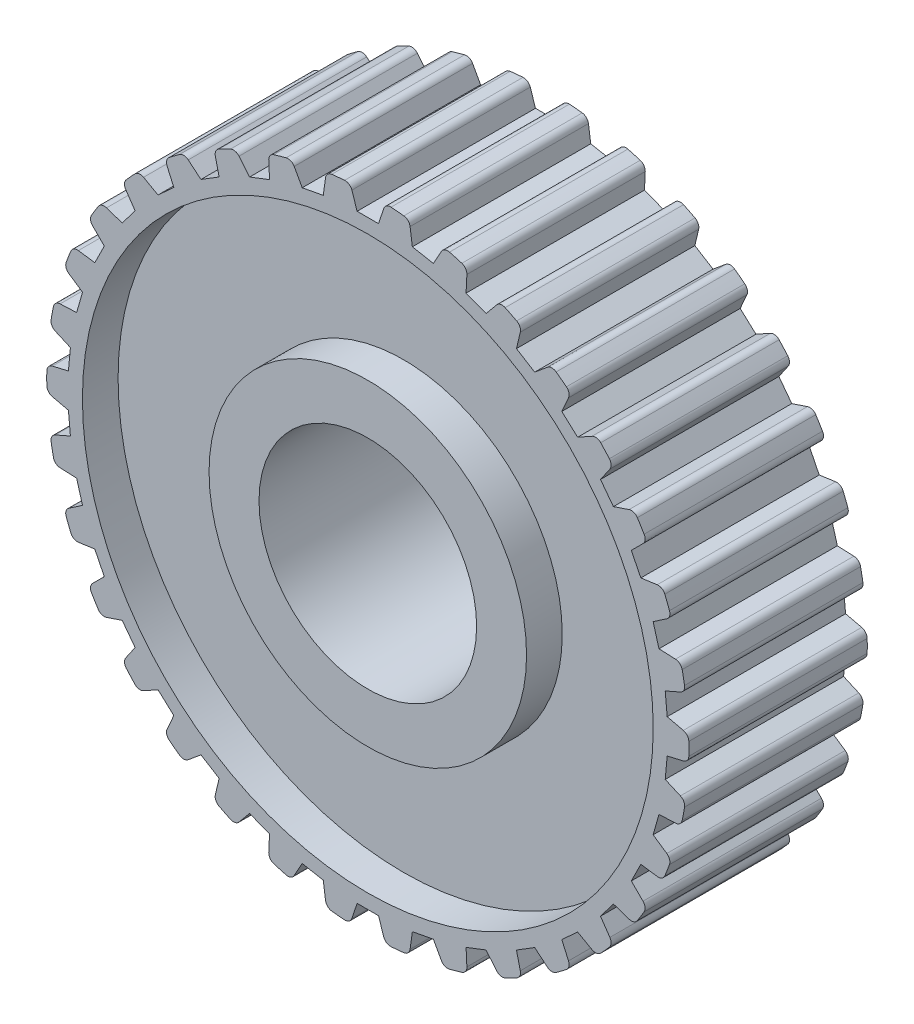
from build123d import *

# Parameters (mm, degrees)
SKETCH1_R                = 45
SKETCH1_R_2              = 40
BOSS_EXTRUDE1_DEPTH      = 25
SKETCH1_R_3              = 22.25
SKETCH1_R_4              = 15.25
BOSS_EXTRUDE1_2_DEPTH    = 25
SKETCH2_R                = 40
SKETCH2_R_2              = 22.25
BOSS_EXTRUDE2_DEPTH      = 7.5
BOSS_EXTRUDE2_DEPTH_BACK = 7.5
CUT_EXTRUDE2_DEPTH       = 26
FILLET1_R                = 1
CIRPATTERN1_COUNT        = 34
FILLET1_OF_CIRPATTERN1_R = 1


with BuildPart() as part:
    # Sketch1 → Boss-Extrude1 (new body)
    with BuildSketch(Plane.XY):
        Circle(SKETCH1_R)
        Circle(SKETCH1_R_2, mode=Mode.SUBTRACT)
    extrude(amount=BOSS_EXTRUDE1_DEPTH)



with BuildPart() as body_2:
    # Sketch1 → Boss-Extrude1 2 (new body)
    with BuildSketch(Plane.XY):
        Circle(SKETCH1_R_3)
        Circle(SKETCH1_R_4, mode=Mode.SUBTRACT)
    extrude(amount=BOSS_EXTRUDE1_2_DEPTH)


with BuildPart() as part_1:
    add(part.part)

    add(body_2.part)  # Boss-Extrude2 merges body 2
    # Sketch2 → Boss-Extrude2 (add, two sides)
    with BuildSketch(Plane.XY.offset(12.5)) as boss_extrude2_sk:
        Circle(SKETCH2_R)
        Circle(SKETCH2_R_2, mode=Mode.SUBTRACT)
    extrude(amount=BOSS_EXTRUDE2_DEPTH)
    extrude(boss_extrude2_sk.sketch, amount=-BOSS_EXTRUDE2_DEPTH_BACK)

    # Sketch4 → Cut-Extrude2 (cut, through all)
    with BuildSketch(Plane.XY.offset(25)):
        Polygon((-2.5, 45), (2.5, 45), (1.5, 42), (0, 42), (-1.5, 42), align=None)
    cut_extrude2 = extrude(amount=-CUT_EXTRUDE2_DEPTH, mode=Mode.SUBTRACT)

    # Fillet1
    fillet1_edges = [part_1.edges().sort_by_distance(p)[0] for p in [
        (-2.477253913, 44.93176174, 12.5),
        (2.477253913, 44.93176174, 12.5),
    ]]
    fillet(fillet1_edges, radius=FILLET1_R)

    # CirPattern1: Cut-Extrude2 ×34 about axis
    cirpattern1_axis = Axis((0, 0, 0), (0, 0, 1))
    for i in range(1, CIRPATTERN1_COUNT):
        add(cut_extrude2.rotate(cirpattern1_axis, i * 360 / CIRPATTERN1_COUNT), mode=Mode.SUBTRACT)

    # Fillet1 of CirPattern1
    fillet1_of_cirpattern1_edges = [part_1.edges().sort_by_distance(p)[0] for p in [
        (-10.691263512, 43.7115189, 12.5),
        (-5.821115596, 44.621907324, 12.5),
        (-18.541194955, 41.002732709, 12.5),
        (-13.921253996, 42.792507372, 12.5),
        (-25.759728241, 36.897647634, 12.5),
        (-21.547320788, 39.505859905, 12.5),
        (-32.101044878, 31.536057423, 12.5),
        (-28.439619413, 34.873887762, 12.5),
        (-37.349198932, 25.100544599, 12.5),
        (-34.363440909, 29.054327197, 12.5),
        (-41.325470812, 17.810262834, 12.5),
        (-39.117056639, 22.245356367, 12.5),
        (-43.894453347, 9.913473928, 12.5),
        (-42.538587921, 14.678846605, 12.5),
        (-44.96866292, 1.679093559, 12.5),
        (-44.511518611, 6.612466328, 12.5),
        (-44.511518611, -6.612466328, 12.5),
        (-44.96866292, -1.679093559, 12.5),
        (-42.538587921, -14.678846605, 12.5),
        (-43.894453347, -9.913473928, 12.5),
        (-39.117056639, -22.245356367, 12.5),
        (-41.325470812, -17.810262834, 12.5),
        (-34.363440909, -29.054327197, 12.5),
        (-37.349198932, -25.100544599, 12.5),
        (-28.439619413, -34.873887762, 12.5),
        (-32.101044878, -31.536057423, 12.5),
        (-21.547320788, -39.505859905, 12.5),
        (-25.759728241, -36.897647634, 12.5),
        (-13.921253996, -42.792507372, 12.5),
        (-18.541194955, -41.002732709, 12.5),
        (-5.821115596, -44.621907324, 12.5),
        (-10.691263512, -43.7115189, 12.5),
        (2.477253913, -44.93176174, 12.5),
        (-2.477253913, -44.93176174, 12.5),
        (10.691263512, -43.7115189, 12.5),
        (5.821115596, -44.621907324, 12.5),
        (18.541194955, -41.002732709, 12.5),
        (13.921253996, -42.792507372, 12.5),
        (25.759728241, -36.897647634, 12.5),
        (21.547320788, -39.505859905, 12.5),
        (32.101044878, -31.536057423, 12.5),
        (28.439619413, -34.873887762, 12.5),
        (37.349198932, -25.100544599, 12.5),
        (34.363440909, -29.054327197, 12.5),
        (41.325470812, -17.810262834, 12.5),
        (39.117056639, -22.245356367, 12.5),
        (43.894453347, -9.913473928, 12.5),
        (42.538587921, -14.678846605, 12.5),
        (44.96866292, -1.679093559, 12.5),
        (44.511518611, -6.612466328, 12.5),
        (44.511518611, 6.612466328, 12.5),
        (44.96866292, 1.679093559, 12.5),
        (42.538587921, 14.678846605, 12.5),
        (43.894453347, 9.913473928, 12.5),
        (39.117056639, 22.245356367, 12.5),
        (41.325470812, 17.810262834, 12.5),
        (34.363440909, 29.054327197, 12.5),
        (37.349198932, 25.100544599, 12.5),
        (28.439619413, 34.873887762, 12.5),
        (32.101044878, 31.536057423, 12.5),
        (21.547320788, 39.505859905, 12.5),
        (25.759728241, 36.897647634, 12.5),
        (13.921253996, 42.792507372, 12.5),
        (18.541194955, 41.002732709, 12.5),
        (5.821115596, 44.621907324, 12.5),
        (10.691263512, 43.7115189, 12.5),
    ]]
    fillet(fillet1_of_cirpattern1_edges, radius=FILLET1_OF_CIRPATTERN1_R)


solid = part_1.part
